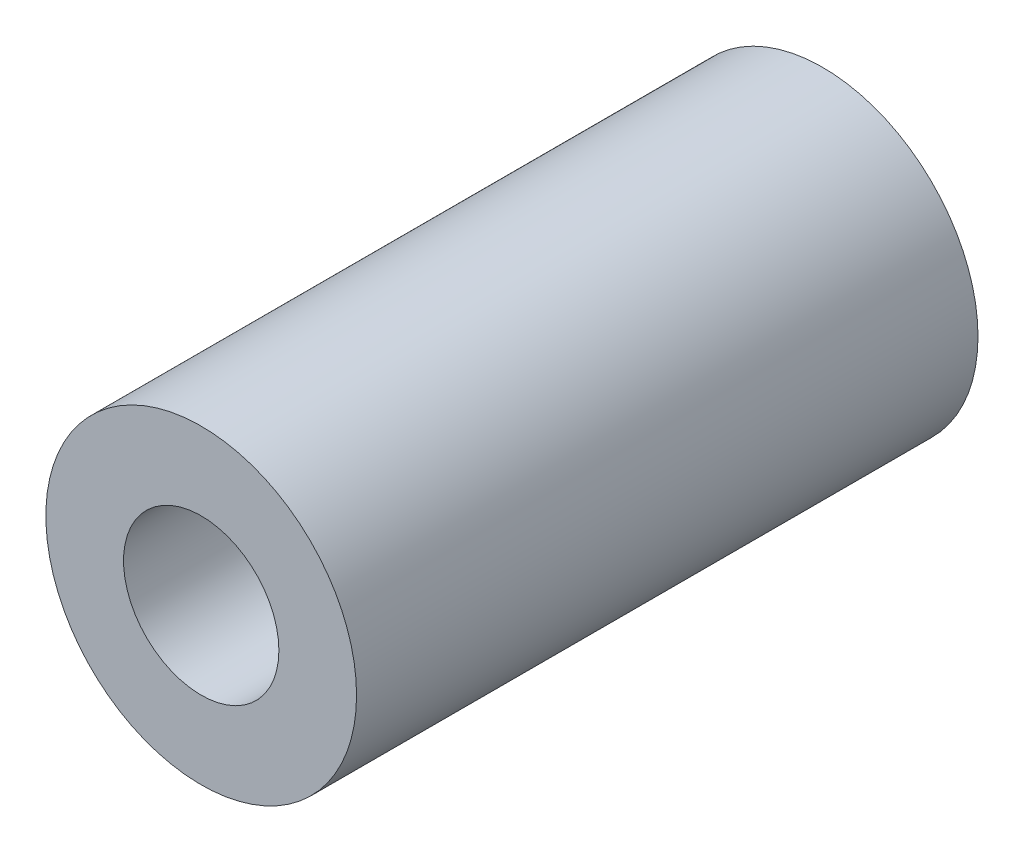
from build123d import *

# Parameters (mm, degrees)
SKETCH1_R           = 5
SKETCH1_R_2         = 2.5
BOSS_EXTRUDE1_DEPTH = 20
SKETCH2_R           = 1.5
CUT_EXTRUDE1_DEPTH  = 10


with BuildPart() as part:
    # Sketch1 → Boss-Extrude1 (new body)
    with BuildSketch(Plane.XY):
        Circle(SKETCH1_R)
        Circle(SKETCH1_R_2, mode=Mode.SUBTRACT)
    extrude(amount=BOSS_EXTRUDE1_DEPTH)

    # Sketch2 → Cut-Extrude1 (cut)
    with BuildSketch(Plane(origin=(0, 0, 0), x_dir=(1, 0, 0), z_dir=(0, 1, 0))):
        with Locations((0.032863465, -5)):
            Circle(SKETCH2_R)
        with Locations((0.098590396, -15)):
            Circle(SKETCH2_R)
    extrude(amount=-CUT_EXTRUDE1_DEPTH, mode=Mode.SUBTRACT)


solid = part.part
